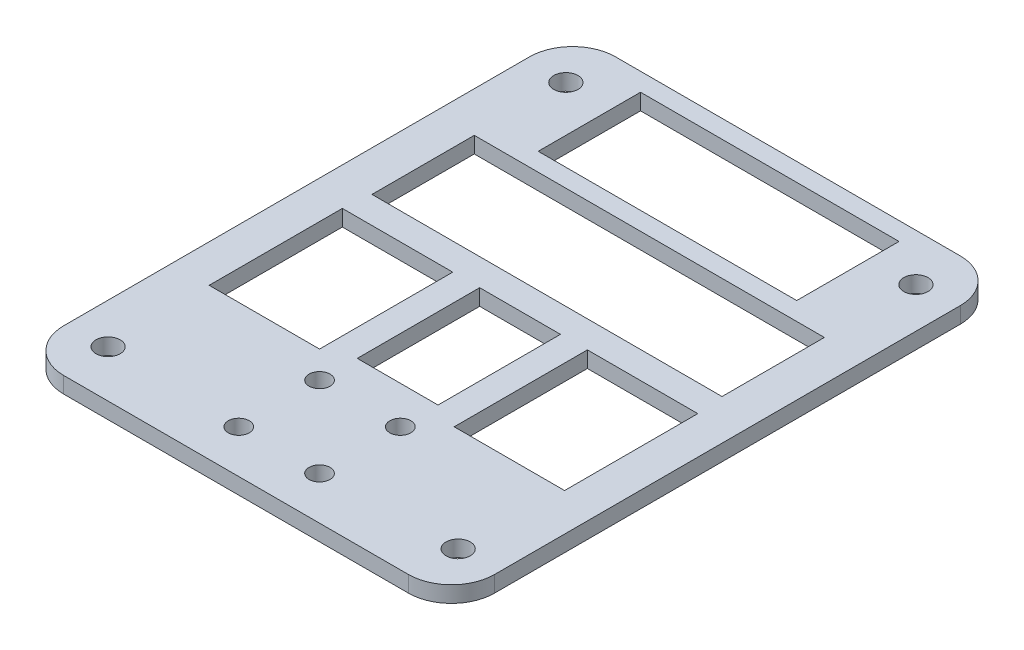
from build123d import *

# Parameters (mm, degrees)
ESQUISSE1_R             = 65
DISQUE_DEPTH            = 3
ESQUISSE3_W             = 30.466369815
ESQUISSE3_H             = 200
COT_S_DEPTH             = 4
D_GAGEMENT_M42_D        = 4.5
ESQUISSE15_W            = 89.863216067
ESQUISSE15_H            = 32.096215679
ENL_V_MAT_EXTRU_1_DEPTH = 4
EMPLACEMENT_COMPOS_W    = 48
EMPLACEMENT_COMPOS_H    = 19
EMPLACEMENT_COMPOS_W_2  = 65
EMPLACEMENT_COMPOS_W_3  = 120.200529509
EMPLACEMENT_COMPOS_H_2  = 30.626013932
ENL_V_MAT_EXTRU_2_DEPTH = 4
CONG_1_R                = 8
D_GAGEMENT_M3_51_D      = 3.9
D_GAGEMENT_M3_51_DEPTH  = 3
D_GAGEMENT_M3_51_TIP    = 1.171678207
ESQUISSE19_W            = 20.5
ESQUISSE19_H            = 24.73475383
ENL_V_MAT_EXTRU_3_DEPTH = 4
ESQUISSE22_W            = 15
ESQUISSE22_H            = 22.73475383
ENL_V_MAT_EXTRU_4_DEPTH = 4


with BuildPart() as part:
    # Esquisse1 → disque (new body)
    with BuildSketch(Plane(origin=(0, 0, 0), x_dir=(1, 0, 0), z_dir=(0, 1, 0))):
        Circle(ESQUISSE1_R)
    extrude(amount=DISQUE_DEPTH)

    # Esquisse3 → cotés (cut, through all)
    with BuildSketch(Plane(origin=(0, 3, 0), x_dir=(1, 0, 0), z_dir=(0, 1, 0))):
        with Locations((-55.233184908, 0)):
            Rectangle(ESQUISSE3_W, ESQUISSE3_H)
        with Locations((55.233184908, 0)):
            Rectangle(ESQUISSE3_W, ESQUISSE3_H)
    extrude(amount=-COT_S_DEPTH, mode=Mode.SUBTRACT)

    # Dégagement M42 (through all)
    with Locations(Plane(origin=(0, 3, 0), x_dir=(1, 0, 0), z_dir=(0, 1, 0))):
        with Locations((-32.5, 42.5), (32.5, 42.5), (32.5, -42.5), (-32.5, -42.5)):
            Hole(D_GAGEMENT_M42_D / 2)

    # Esquisse15 → Enlèv. mat.-Extru.1 (cut, through all)
    with BuildSketch(Plane.XZ):
        with Locations((-4.931608034, 67.282861669)):
            Rectangle(ESQUISSE15_W, ESQUISSE15_H)
    extrude(amount=-ENL_V_MAT_EXTRU_1_DEPTH, mode=Mode.SUBTRACT)

    # emplacement compos → Enlèv. mat.-Extru.2 (cut, through all)
    with BuildSketch(Plane(origin=(0, 0, 0), x_dir=(-1, 0, 0), z_dir=(0, -1, 0))):
        with Locations((0, 38.367376915)):
            Rectangle(EMPLACEMENT_COMPOS_W, EMPLACEMENT_COMPOS_H)
        with Locations((0, 16)):
            Rectangle(EMPLACEMENT_COMPOS_W_2, EMPLACEMENT_COMPOS_H)
        with Locations((-20.100264755, 66.547760796)):
            Rectangle(EMPLACEMENT_COMPOS_W_3, EMPLACEMENT_COMPOS_H_2)
    extrude(amount=-ENL_V_MAT_EXTRU_2_DEPTH, mode=Mode.SUBTRACT)

    # Congé1
    cong_1_edges = [part.edges().sort_by_distance(p)[0] for p in [
        (40, 1.5, -51.23475383),
        (40, 1.5, 51.23475383),
        (-40, 1.5, 51.23475383),
        (-40, 1.5, -51.23475383),
    ]]
    fillet(cong_1_edges, radius=CONG_1_R)

    # Dégagement M3.51
    with Locations(Plane(origin=(0, 3, 0), x_dir=(1, 0, 0), z_dir=(0, 1, 0))):
        with Locations((-7.5, -28.23475383), (7.5, -28.23475383), (7.5, -43.23475383), (-7.5, -43.23475383)):
            Hole(D_GAGEMENT_M3_51_D / 2, depth=D_GAGEMENT_M3_51_DEPTH)
            with Locations((0, 0, -(D_GAGEMENT_M3_51_DEPTH + D_GAGEMENT_M3_51_TIP / 2))):  # 118° drill point
                Cone(0, D_GAGEMENT_M3_51_D / 2, D_GAGEMENT_M3_51_TIP, mode=Mode.SUBTRACT)

    # Esquisse19 → Enlèv. mat.-Extru.3 (cut, through all)
    with BuildSketch(Plane(origin=(0, 3, 0), x_dir=(1, 0, 0), z_dir=(0, 1, 0))):
        with Locations((-22.75, -10.867376915)):
            Rectangle(ESQUISSE19_W, ESQUISSE19_H)
    enl_v_mat_extru_3 = extrude(amount=-ENL_V_MAT_EXTRU_3_DEPTH, mode=Mode.SUBTRACT)

    # Symétrie1: Enlèv. mat.-Extru.3 across plane
    add(enl_v_mat_extru_3.mirror(Plane.ZY), mode=Mode.SUBTRACT)

    # Esquisse22 → Enlèv. mat.-Extru.4 (cut, through all)
    with BuildSketch(Plane(origin=(0, 3, 0), x_dir=(1, 0, 0), z_dir=(0, 1, 0))):
        with Locations((0, -9.867376915)):
            Rectangle(ESQUISSE22_W, ESQUISSE22_H)
    extrude(amount=-ENL_V_MAT_EXTRU_4_DEPTH, mode=Mode.SUBTRACT)


solid = part.part
